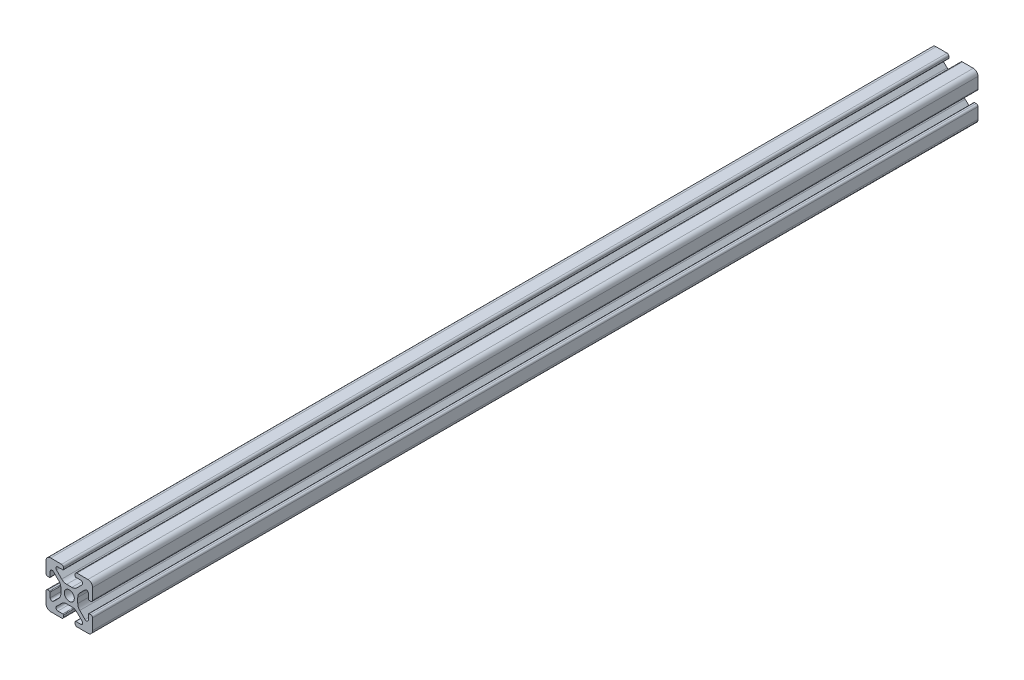
from build123d import *

# Parameters (mm, degrees)
SKETCH1_R           = 2.1463
BOSS_EXTRUDE1_DEPTH = 190


with BuildPart() as part:
    # Sketch1 → Boss-Extrude1 (new body, symmetric)
    with BuildSketch(Plane.XY):
        with BuildLine():
            Line((-9.9949, 7.9883), (-9.9949, 3.2893))
            ThreePointArc((-9.9949, 3.2893), (-9.76427588, 2.73252412), (-9.2075, 2.5019))
            Line((-9.2075, 2.5019), (-8.4963, 2.5019))
            ThreePointArc((-8.4963, 2.5019), (-8.280773853, 2.591173853), (-8.1915, 2.8067))
            Line((-8.1915, 2.8067), (-8.1915, 4.9149))
            ThreePointArc((-8.1915, 4.9149), (-7.674065253, 5.689295824), (-6.760603096, 5.507596904))
            Line((-6.760603096, 5.507596904), (-4.505765747, 3.252759555))
            ThreePointArc((-4.505765747, 3.252759555), (-3.856054457, 2.280397894), (-3.627906192, 1.133419111))
            Line((-3.627906192, 1.133419111), (-3.627906192, -1.133419111))
            ThreePointArc((-3.627906192, -1.133419111), (-3.856054457, -2.280397894), (-4.505765747, -3.252759555))
            Line((-4.505765747, -3.252759555), (-6.760603096, -5.507596904))
            ThreePointArc((-6.760603096, -5.507596904), (-7.674065253, -5.689295824), (-8.1915, -4.9149))
            Line((-8.1915, -4.9149), (-8.1915, -2.8067))
            ThreePointArc((-8.1915, -2.8067), (-8.280773853, -2.591173853), (-8.4963, -2.5019))
            Line((-8.4963, -2.5019), (-9.2075, -2.5019))
            ThreePointArc((-9.2075, -2.5019), (-9.76427588, -2.73252412), (-9.9949, -3.2893))
            Line((-9.9949, -3.2893), (-9.9949, -7.9883))
            ThreePointArc((-9.9949, -7.9883), (-9.407180467, -9.407180467), (-7.9883, -9.9949))
            Line((-7.9883, -9.9949), (-3.2893, -9.9949))
            ThreePointArc((-3.2893, -9.9949), (-2.73252412, -9.76427588), (-2.5019, -9.2075))
            Line((-2.5019, -9.2075), (-2.5019, -8.4963))
            ThreePointArc((-2.5019, -8.4963), (-2.591173853, -8.280773853), (-2.8067, -8.1915))
            Line((-2.8067, -8.1915), (-4.9149, -8.1915))
            ThreePointArc((-4.9149, -8.1915), (-5.689295824, -7.674065253), (-5.507596904, -6.760603096))
            Line((-5.507596904, -6.760603096), (-3.252759555, -4.505765747))
            ThreePointArc((-3.252759555, -4.505765747), (-2.280397894, -3.856054457), (-1.133419111, -3.627906192))
            Line((-1.133419111, -3.627906192), (1.133419111, -3.627906192))
            ThreePointArc((1.133419111, -3.627906192), (2.280397894, -3.856054457), (3.252759555, -4.505765747))
            Line((3.252759555, -4.505765747), (5.507596904, -6.760603096))
            ThreePointArc((5.507596904, -6.760603096), (5.689295824, -7.674065253), (4.9149, -8.1915))
            Line((4.9149, -8.1915), (2.8067, -8.1915))
            ThreePointArc((2.8067, -8.1915), (2.591173853, -8.280773853), (2.5019, -8.4963))
            Line((2.5019, -8.4963), (2.5019, -9.2075))
            ThreePointArc((2.5019, -9.2075), (2.73252412, -9.76427588), (3.2893, -9.9949))
            Line((3.2893, -9.9949), (7.9883, -9.9949))
            ThreePointArc((7.9883, -9.9949), (9.407180467, -9.407180467), (9.9949, -7.9883))
            Line((9.9949, -7.9883), (9.9949, -3.2893))
            ThreePointArc((9.9949, -3.2893), (9.76427588, -2.73252412), (9.2075, -2.5019))
            Line((9.2075, -2.5019), (8.4963, -2.5019))
            ThreePointArc((8.4963, -2.5019), (8.280773853, -2.591173853), (8.1915, -2.8067))
            Line((8.1915, -2.8067), (8.1915, -4.9149))
            ThreePointArc((8.1915, -4.9149), (7.674065253, -5.689295824), (6.760603096, -5.507596904))
            Line((6.760603096, -5.507596904), (4.505765747, -3.252759555))
            ThreePointArc((4.505765747, -3.252759555), (3.856054457, -2.280397894), (3.627906192, -1.133419111))
            Line((3.627906192, -1.133419111), (3.627906192, 1.133419111))
            ThreePointArc((3.627906192, 1.133419111), (3.856054457, 2.280397894), (4.505765747, 3.252759555))
            Line((4.505765747, 3.252759555), (6.760603096, 5.507596904))
            ThreePointArc((6.760603096, 5.507596904), (7.674065253, 5.689295824), (8.1915, 4.9149))
            Line((8.1915, 4.9149), (8.1915, 2.8067))
            ThreePointArc((8.1915, 2.8067), (8.280773853, 2.591173853), (8.4963, 2.5019))
            Line((8.4963, 2.5019), (9.2075, 2.5019))
            ThreePointArc((9.2075, 2.5019), (9.76427588, 2.73252412), (9.9949, 3.2893))
            Line((9.9949, 3.2893), (9.9949, 7.9883))
            ThreePointArc((9.9949, 7.9883), (9.407180467, 9.407180467), (7.9883, 9.9949))
            Line((7.9883, 9.9949), (3.2893, 9.9949))
            ThreePointArc((3.2893, 9.9949), (2.73252412, 9.76427588), (2.5019, 9.2075))
            Line((2.5019, 9.2075), (2.5019, 8.4963))
            ThreePointArc((2.5019, 8.4963), (2.591173853, 8.280773853), (2.8067, 8.1915))
            Line((2.8067, 8.1915), (4.9149, 8.1915))
            ThreePointArc((4.9149, 8.1915), (5.689295824, 7.674065253), (5.507596904, 6.760603096))
            Line((5.507596904, 6.760603096), (3.252759555, 4.505765747))
            ThreePointArc((3.252759555, 4.505765747), (2.280397894, 3.856054457), (1.133419111, 3.627906192))
            Line((1.133419111, 3.627906192), (-1.133419111, 3.627906192))
            ThreePointArc((-1.133419111, 3.627906192), (-2.280397894, 3.856054457), (-3.252759555, 4.505765747))
            Line((-3.252759555, 4.505765747), (-5.507596904, 6.760603096))
            ThreePointArc((-5.507596904, 6.760603096), (-5.689295824, 7.674065253), (-4.9149, 8.1915))
            Line((-4.9149, 8.1915), (-2.8067, 8.1915))
            ThreePointArc((-2.8067, 8.1915), (-2.591173853, 8.280773853), (-2.5019, 8.4963))
            Line((-2.5019, 8.4963), (-2.5019, 9.2075))
            ThreePointArc((-2.5019, 9.2075), (-2.73252412, 9.76427588), (-3.2893, 9.9949))
            Line((-3.2893, 9.9949), (-7.9883, 9.9949))
            ThreePointArc((-7.9883, 9.9949), (-9.407180467, 9.407180467), (-9.9949, 7.9883))
        make_face()
        Circle(SKETCH1_R, mode=Mode.SUBTRACT)
    extrude(amount=BOSS_EXTRUDE1_DEPTH, both=True)


solid = part.part
